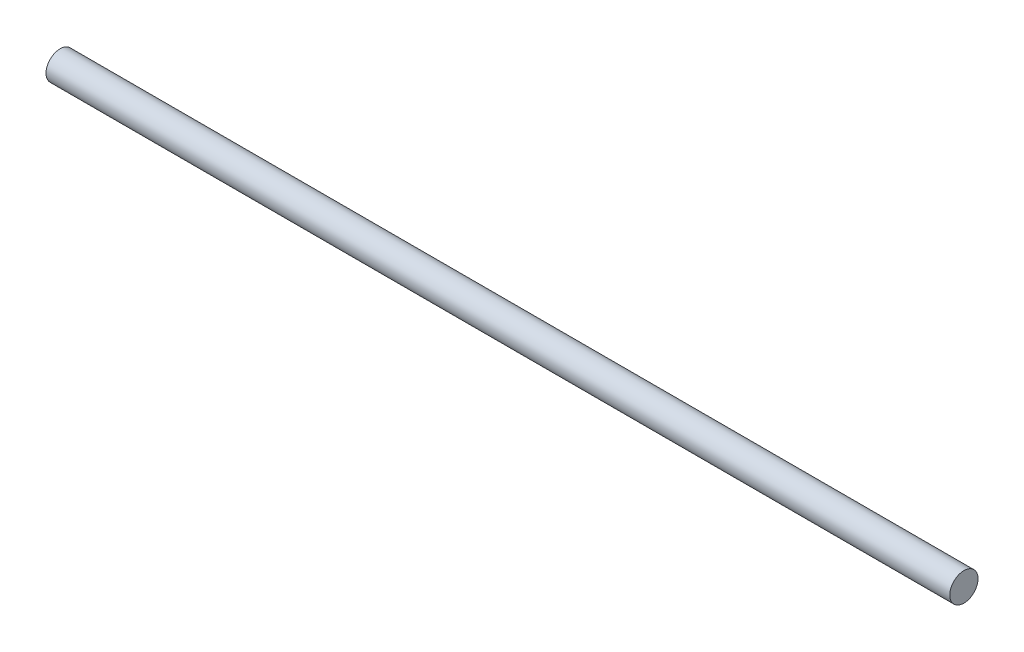
from build123d import *

# Parameters (mm, degrees)
SWEEP1_PROFILE_R = 9.525


with BuildPart() as part:
    # Sweep1: sweep along a path in Sketch1
    with BuildLine(Plane(origin=(0, 0, 0), x_dir=(1, 0, 0), z_dir=(0, 1, 0))) as sweep1_path:
        Line((0, 0), (-609.6, 0))
    # Sweep1 profile (on start of the path) → Sweep1 (sweep)
    with BuildSketch(Plane(origin=(0, 0, 0), x_dir=(0, 0, -1), z_dir=(-1, 0, 0))):
        Circle(SWEEP1_PROFILE_R)
    sweep(path=sweep1_path.line)


solid = part.part
